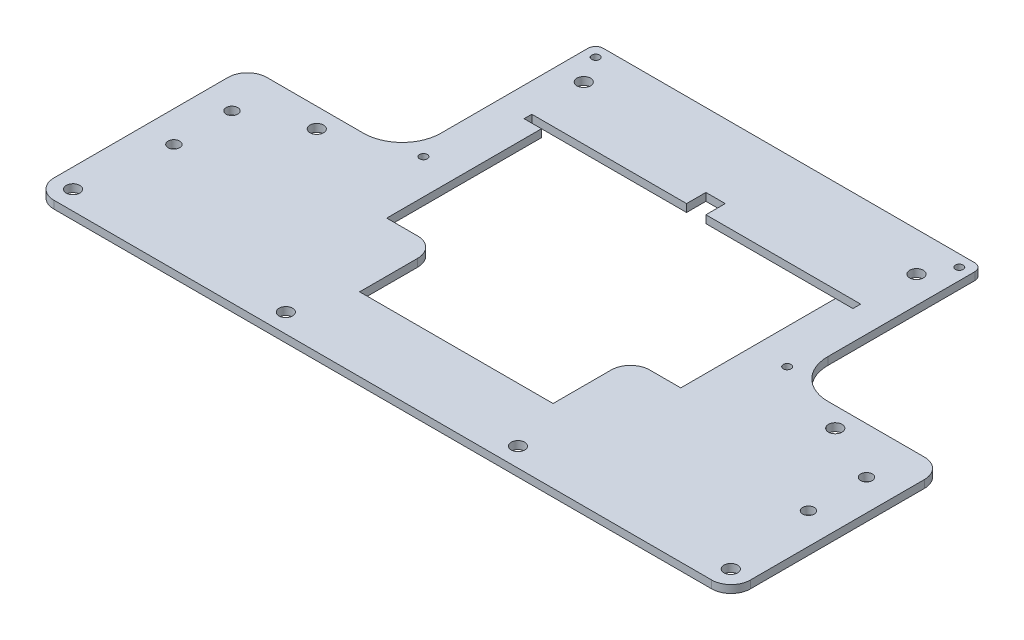
from build123d import *

# Parameters (mm, degrees)
SKETCH1_R           = 1.75
SKETCH1_R_2         = 1
BOSS_EXTRUDE1_DEPTH = 2
SKETCH3_R           = 1.75
SKETCH3_W           = 40
SKETCH3_H           = 10
CUT_EXTRUDE2_DEPTH  = 10
FILLET1_R           = 2
FILLET2_R           = 5
FILLET3_R           = 10
SKETCH4_R           = 1.5
CUT_EXTRUDE3_DEPTH  = 10


with BuildPart() as part:
    # Sketch1 → Boss-Extrude1 (new body)
    with BuildSketch(Plane(origin=(0, 0, 0), x_dir=(1, 0, 0), z_dir=(0, 1, 0))):
        Polygon((-90, 32.535953793), (-90, -32.464046207), (90, -32.464046207), (90, 32.535953793), (50, 32.535953793), (50, 72.535953793), (-50, 72.535953793), (-50, 32.535953793), align=None)
        with Locations((-85, -27.535953793)):
            Circle(SKETCH1_R, mode=Mode.SUBTRACT)
        with Locations((85, -27.535953793)):
            Circle(SKETCH1_R, mode=Mode.SUBTRACT)
        with Locations((-30, -27.535953793)):
            Circle(SKETCH1_R, mode=Mode.SUBTRACT)
        with Locations((30, -27.535953793)):
            Circle(SKETCH1_R, mode=Mode.SUBTRACT)
        with Locations((-67, 17.464046207)):
            Circle(SKETCH1_R, mode=Mode.SUBTRACT)
        with Locations((67, 17.464046207)):
            Circle(SKETCH1_R, mode=Mode.SUBTRACT)
        with Locations((-47, 69.535953793)):
            Circle(SKETCH1_R_2, mode=Mode.SUBTRACT)
        with Locations((-47, 25.035953793)):
            Circle(SKETCH1_R_2, mode=Mode.SUBTRACT)
        with Locations((47, 25.035953793)):
            Circle(SKETCH1_R_2, mode=Mode.SUBTRACT)
        with Locations((47, 69.535953793)):
            Circle(SKETCH1_R_2, mode=Mode.SUBTRACT)
    extrude(amount=BOSS_EXTRUDE1_DEPTH)

    # Sketch3 → Cut-Extrude2 (cut)
    with BuildSketch(Plane(origin=(0, 2, 0), x_dir=(1, 0, 0), z_dir=(0, 1, 0))):
        with Locations((-43, 62.464046207)):
            Circle(SKETCH3_R)
        with Locations((43, 62.464046207)):
            Circle(SKETCH3_R)
        Polygon((2.5, 48.535953793), (42.5, 48.535953793), (42.5, 46.535953793), (38, 46.535953793), (38, 6.535953793), (25, 6.535953793), (25, -13.464046207), (-25, -13.464046207), (-25, 6.535953793), (-38, 6.535953793), (-38, 46.535953793), (-42.5, 46.535953793), (-42.5, 48.535953793), (-2.5, 48.535953793), (-2.5, 53.535953793), (2.5, 53.535953793), align=None)
        with Locations((70, 27.535953793)):
            Rectangle(SKETCH3_W, SKETCH3_H)
        with Locations((-70, 27.535953793)):
            Rectangle(SKETCH3_W, SKETCH3_H)
    extrude(amount=-CUT_EXTRUDE2_DEPTH, mode=Mode.SUBTRACT)

    # Fillet1
    fillet1_edges = [part.edges().sort_by_distance(p)[0] for p in [
        (-50, 1, -72.535953793),
        (50, 1, -72.535953793),
    ]]
    fillet(fillet1_edges, radius=FILLET1_R)

    # Fillet2
    fillet2_edges = [part.edges().sort_by_distance(p)[0] for p in [
        (90, 1, -22.535953793),
        (25, 1, -6.535953793),
        (-25, 1, -6.535953793),
        (90, 1, 32.464046207),
        (-90, 1, 32.464046207),
        (-90, 1, -22.535953793),
    ]]
    fillet(fillet2_edges, radius=FILLET2_R)

    # Fillet3
    fillet3_edges = [part.edges().sort_by_distance(p)[0] for p in [
        (50, 1, -22.535953793),
        (-50, 1, -22.535953793),
    ]]
    fillet(fillet3_edges, radius=FILLET3_R)

    # Sketch4 → Cut-Extrude3 (cut)
    with BuildSketch(Plane(origin=(0, 2, 0), x_dir=(1, 0, 0), z_dir=(0, 1, 0))):
        with Locations((-82, 10.535953793)):
            Circle(SKETCH4_R)
        with Locations((-82, -4.464046207)):
            Circle(SKETCH4_R)
        with Locations((82, 10.535953793)):
            Circle(SKETCH4_R)
        with Locations((82, -4.464046207)):
            Circle(SKETCH4_R)
    extrude(amount=-CUT_EXTRUDE3_DEPTH, mode=Mode.SUBTRACT)


solid = part.part
